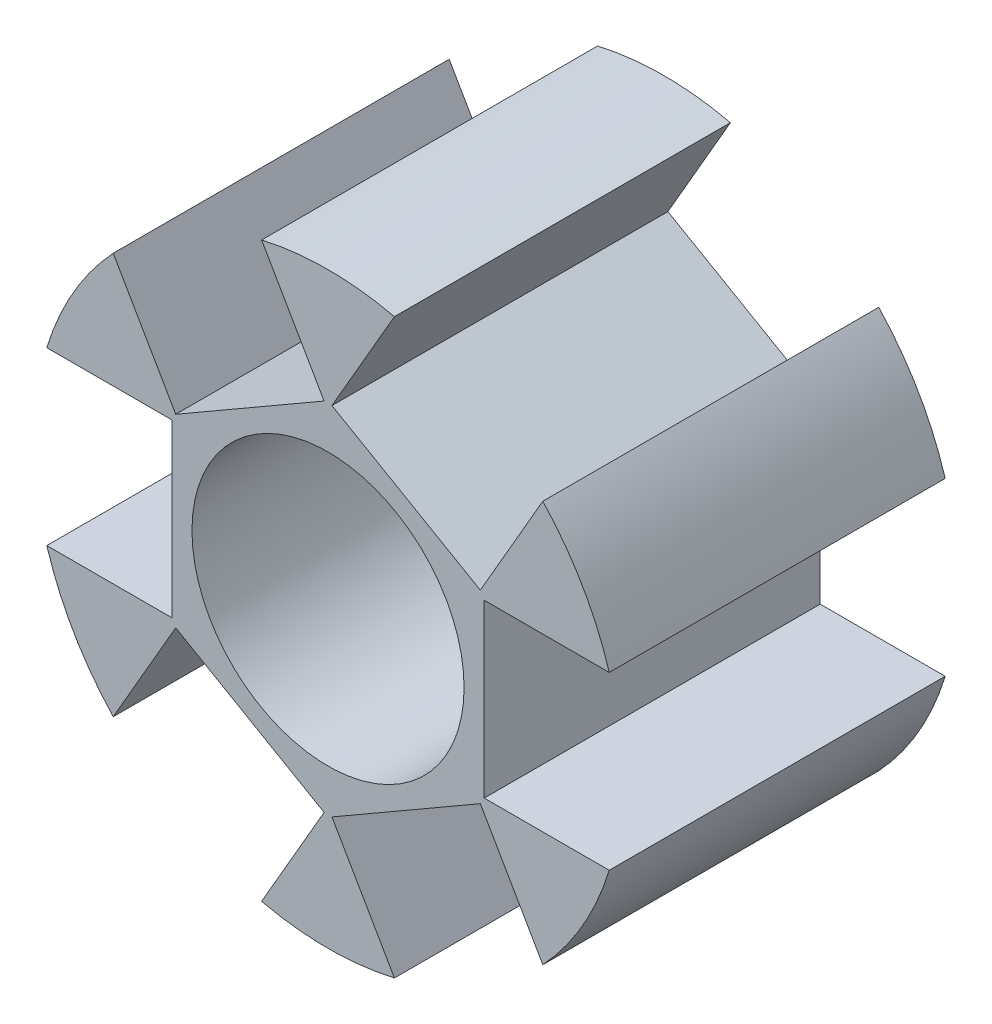
from build123d import *

# Parameters (mm, degrees)
SKETCH1_R           = 8.75
SKETCH1_R_2         = 4.05
BOSS_EXTRUDE1_DEPTH = 5
SKETCH2_W           = 5.1
SKETCH2_H           = 10
CUT_EXTRUDE3_DEPTH  = 4.1
CIRPATTERN1_COUNT   = 6


with BuildPart() as part:
    # Sketch1 → Boss-Extrude1 (new, symmetric)
    with BuildSketch(Plane.XY):
        Circle(SKETCH1_R)
        Circle(SKETCH1_R_2, mode=Mode.SUBTRACT)
    extrude(amount=BOSS_EXTRUDE1_DEPTH, both=True)

    # Sketch2 → Cut-Extrude3 (cut)
    with BuildSketch(Plane(origin=(-8.75, -17.193061184, 0), x_dir=(0, -1, 0), z_dir=(1, 0, 0))):
        with Locations((-17.193061184, 0)):
            Rectangle(SKETCH2_W, SKETCH2_H)
    cut_extrude3 = extrude(amount=CUT_EXTRUDE3_DEPTH, mode=Mode.SUBTRACT)

    # CirPattern1: Cut-Extrude3 ×6 about axis
    cirpattern1_axis = Axis((0, 0, 5), (0, 0, 1))
    for i in range(1, CIRPATTERN1_COUNT):
        add(cut_extrude3.rotate(cirpattern1_axis, i * 360 / CIRPATTERN1_COUNT), mode=Mode.SUBTRACT)


solid = part.part
